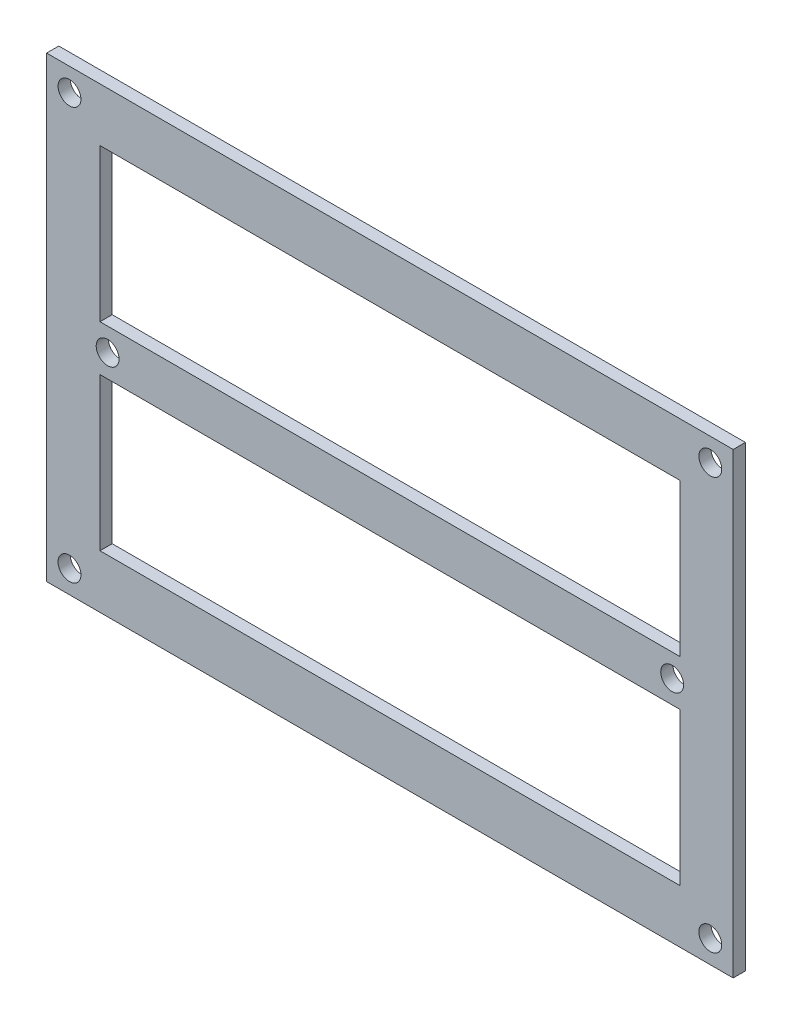
from build123d import *

# Parameters (mm, degrees)
SKETCH_2_W          = 90
SKETCH_2_H          = 60
EXTRUDE_1_DEPTH     = 1.6
SKETCH_3_R          = 1.5
SKETCH_3_W          = 76
SKETCH_3_H          = 20
CUT_EXTRUDE_1_DEPTH = 2.6


with BuildPart() as part:
    # ｽｹｯﾁ2 → ﾎﾞｽ - 押し出し1 (new body)
    with BuildSketch(Plane.XY):
        with Locations((-10.192982456, -2.631578947)):
            Rectangle(SKETCH_2_W, SKETCH_2_H)
    extrude(amount=EXTRUDE_1_DEPTH)

    # ｽｹｯﾁ3 → ｶｯﾄ - 押し出し1 (cut, through all)
    with BuildSketch(Plane(origin=(0, 0, 0), x_dir=(-1, 0, 0), z_dir=(0, 0, -1))):
        with Locations((47.192982456, -2.631578947)):
            Circle(SKETCH_3_R)
        with Locations((-26.807017544, -2.631578947)):
            Circle(SKETCH_3_R)
        with Locations((52.192982456, 24.368421053)):
            Circle(SKETCH_3_R)
        with Locations((-31.807017544, 24.368421053)):
            Circle(SKETCH_3_R)
        with Locations((-31.807017544, -29.631578947)):
            Circle(SKETCH_3_R)
        with Locations((52.192982456, -29.631578947)):
            Circle(SKETCH_3_R)
        with Locations((10.192982456, 10.368421053)):
            Rectangle(SKETCH_3_W, SKETCH_3_H)
        with Locations((10.192982456, -15.631578947)):
            Rectangle(SKETCH_3_W, SKETCH_3_H)
    extrude(amount=-CUT_EXTRUDE_1_DEPTH, mode=Mode.SUBTRACT)


solid = part.part
